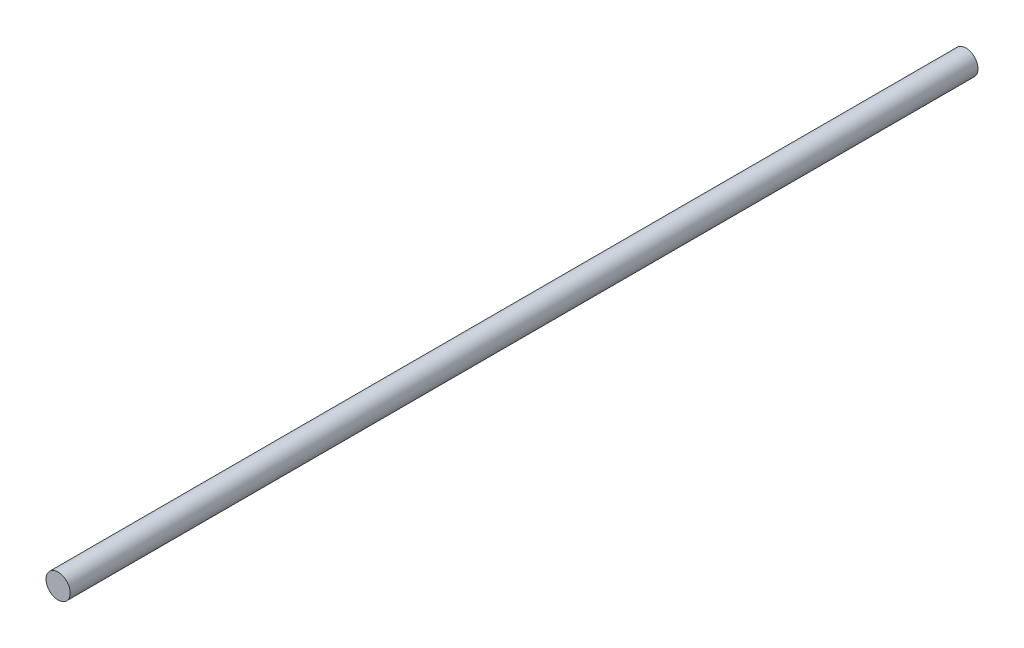
from build123d import *

# Parameters (mm, degrees)
ESBO_O1_R                = 4
RESSALTO_EXTRUS_O1_DEPTH = 300


with BuildPart() as part:
    # Esboço1 → Ressalto-extrusão1 (new body)
    with BuildSketch(Plane.XY):
        Circle(ESBO_O1_R)
    extrude(amount=RESSALTO_EXTRUS_O1_DEPTH)


solid = part.part
